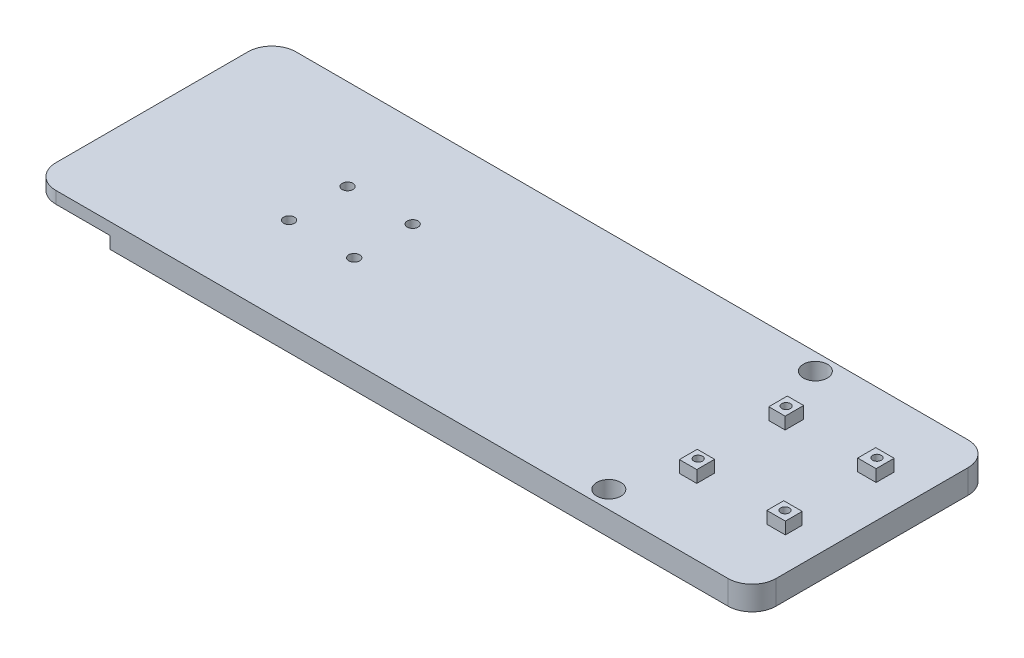
from build123d import *

# Parameters (mm, degrees)
SKETCH2_W               = 300
SKETCH2_H               = 100
BOSS_EXTRUDE1_DEPTH     = 10
SKETCH3_W               = 32.480865485
SKETCH3_H               = 5
CUT_EXTRUDE4_DEPTH      = 100
FILLET2_R               = 10
FILLET3_R               = 10
SKETCH6_R               = 1.8
CUT_EXTRUDE11_DEPTH     = 100
SKETCH10_W              = 6.800425214
SKETCH10_H              = 7.704447869
SKETCH10_R              = 1.8
SKETCH10_W_2            = 7.232198243
SKETCH10_H_2            = 7.417822841
SKETCH10_W_3            = 7.704447868
SKETCH10_H_3            = 7.016311729
SKETCH10_W_4            = 7.663971273
SKETCH10_H_4            = 7.516208799
BOSS_EXTRUDE3_DEPTH     = 5
SKETCH11_R              = 5.007661082
CUT_EXTRUDE13_DEPTH     = 30
CROQUIS2_W              = 7.110286561
CROQUIS2_H              = 33
CROQUIS2_W_2            = 8.127928254
SALIENTE_EXTRUIR1_DEPTH = 15
SKETCH8_R               = 2.25
CORTAR_EXTRUIR1_DEPTH   = 50


with BuildPart() as part:
    # Sketch2 → Boss-Extrude1 (new body)
    with BuildSketch(Plane(origin=(0, 0, 0), x_dir=(1, 0, 0), z_dir=(0, 1, 0))):
        with Locations((30.996437266, 14.831990454)):
            Rectangle(SKETCH2_W, SKETCH2_H)
    extrude(amount=BOSS_EXTRUDE1_DEPTH)

    # Sketch3 → Cut-Extrude4 (cut)
    with BuildSketch(Plane.XY.offset(35.168009546)):
        with Locations((-102.763129992, 2.5)):
            Rectangle(SKETCH3_W, SKETCH3_H)
    extrude(amount=-CUT_EXTRUDE4_DEPTH, mode=Mode.SUBTRACT)

    # Fillet2
    fillet2_edges = [part.edges().sort_by_distance(p)[0] for p in [
        (180.996437266, 5, -64.831990454),
        (180.996437266, 5, 35.168009546),
    ]]
    fillet(fillet2_edges, radius=FILLET2_R)

    # Fillet3
    fillet3_edges = [part.edges().sort_by_distance(p)[0] for p in [
        (-119.003562734, 7.5, -64.831990454),
        (-119.003562734, 7.5, 35.168009546),
    ]]
    fillet(fillet3_edges, radius=FILLET3_R)

    # Sketch6 → Cut-Extrude11 (cut)
    with BuildSketch(Plane(origin=(0, 10, 0), x_dir=(1, 0, 0), z_dir=(0, 1, 0))):
        with Locations((125.905144225, 34.121382773)):
            Circle(SKETCH6_R)
        with Locations((126.546416062, -3.163994016)):
            Circle(SKETCH6_R)
        with Locations((163.282131276, -3.71365559)):
            Circle(SKETCH6_R)
        with Locations((163.465351801, 34.39621356)):
            Circle(SKETCH6_R)
    extrude(amount=-CUT_EXTRUDE11_DEPTH, mode=Mode.SUBTRACT)

    # Sketch10 → Boss-Extrude3 (add)
    with BuildSketch(Plane(origin=(0, 10, 0), x_dir=(1, 0, 0), z_dir=(0, 1, 0))):
        with Locations((125.922054042, 34.139208999)):
            Rectangle(SKETCH10_W, SKETCH10_H)
        with Locations((125.905144225, 34.121382773)):
            Circle(SKETCH10_R, mode=Mode.SUBTRACT)
        with Locations((126.569713587, -3.685857636)):
            Rectangle(SKETCH10_W_2, SKETCH10_H_2)
        with Locations((126.546416062, -3.163994016)):
            Circle(SKETCH10_R, mode=Mode.SUBTRACT)
        with Locations((163.380664231, -4.024818367)):
            Rectangle(SKETCH10_W_3, SKETCH10_H_3)
        with Locations((163.282131276, -3.71365559)):
            Circle(SKETCH10_R, mode=Mode.SUBTRACT)
        with Locations((163.378364349, 34.045089464)):
            Rectangle(SKETCH10_W_4, SKETCH10_H_4)
        with Locations((163.465351801, 34.39621356)):
            Circle(SKETCH10_R, mode=Mode.SUBTRACT)
    extrude(amount=BOSS_EXTRUDE3_DEPTH)

    # Sketch11 → Cut-Extrude13 (cut)
    with BuildSketch(Plane(origin=(0, 10, 0), x_dir=(1, 0, 0), z_dir=(0, 1, 0))):
        with Locations((114.379298218, 57.815546059)):
            Circle(SKETCH11_R)
        with Locations((113.986464963, -27.822103537)):
            Circle(SKETCH11_R)
    extrude(amount=-CUT_EXTRUDE13_DEPTH, mode=Mode.SUBTRACT)

    # Croquis2 → Saliente-Extruir1 (add)
    with BuildSketch(Plane.XZ):
        with Locations((-22.680335873, -14.831990454)):
            Rectangle(CROQUIS2_W, CROQUIS2_H)
        with Locations((-49.939598607, -14.831990454)):
            Rectangle(CROQUIS2_W_2, CROQUIS2_H)
    extrude(amount=SALIENTE_EXTRUIR1_DEPTH)

    # Sketch8 → Cortar-Extruir1 (cut)
    with BuildSketch(Plane(origin=(0, 10, 0), x_dir=(1, 0, 0), z_dir=(0, 1, 0))):
        with Locations((-49.690211369, 27.018639088)):
            Circle(SKETCH8_R)
        with Locations((-49.690211369, 2.645341819)):
            Circle(SKETCH8_R)
        with Locations((-22.549681442, 27.018639088)):
            Circle(SKETCH8_R)
        with Locations((-22.549681442, 2.645341819)):
            Circle(SKETCH8_R)
    extrude(amount=-CORTAR_EXTRUIR1_DEPTH, mode=Mode.SUBTRACT)


solid = part.part
